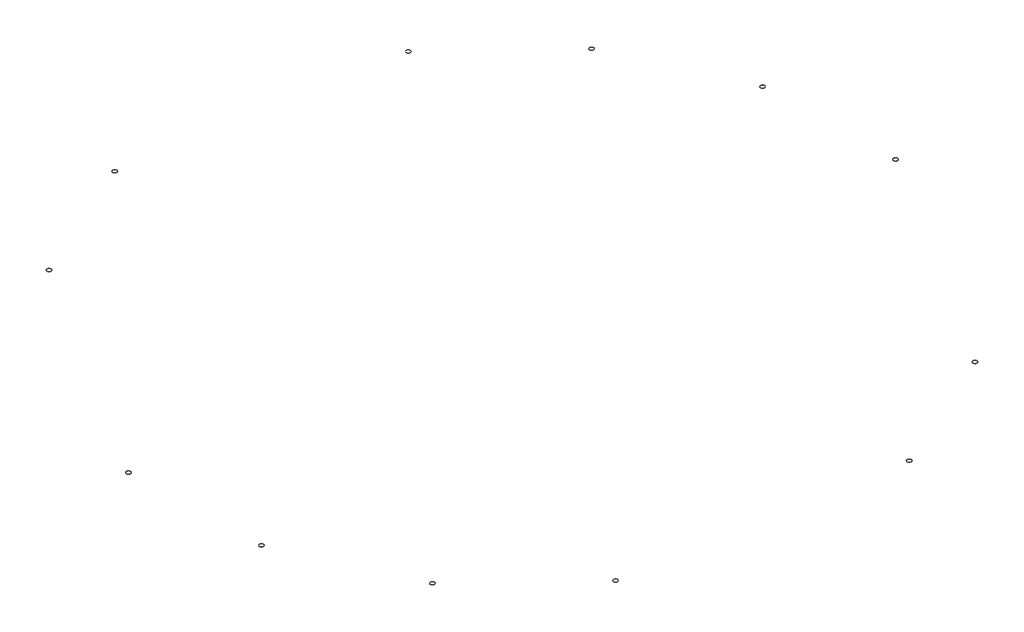
from build123d import *

# Parameters (mm, degrees)
SKETCH2_R              = 25.4
SKETCH2_R_2            = 22.225
BOSS_EXTRUDE1_DEPTH    = 3.175
BOSS_EXTRUDE1_2_DEPTH  = 3.175
BOSS_EXTRUDE1_3_DEPTH  = 3.175
BOSS_EXTRUDE1_4_DEPTH  = 3.175
BOSS_EXTRUDE1_5_DEPTH  = 3.175
BOSS_EXTRUDE1_6_DEPTH  = 3.175
BOSS_EXTRUDE1_7_DEPTH  = 3.175
BOSS_EXTRUDE1_8_DEPTH  = 3.175
BOSS_EXTRUDE1_9_DEPTH  = 3.175
BOSS_EXTRUDE1_10_DEPTH = 3.175
BOSS_EXTRUDE1_11_DEPTH = 3.175
BOSS_EXTRUDE1_12_DEPTH = 3.175


with BuildPart() as part:
    # Sketch2 → Boss-Extrude1 (new body)
    with BuildSketch(Plane(origin=(0, 0, 0), x_dir=(1, 0, 0), z_dir=(0, 1, 0))):
        with Locations((-3790.37532596, -857.674371981)):
            Circle(SKETCH2_R)
        with Locations((-3790.37532596, -857.674371981)):
            Circle(SKETCH2_R_2, mode=Mode.SUBTRACT)
    extrude(amount=BOSS_EXTRUDE1_DEPTH)


with BuildPart() as body_2:
    # Sketch2 → Boss-Extrude1 2 (new body)
    with BuildSketch(Plane(origin=(0, 0, 0), x_dir=(1, 0, 0), z_dir=(0, 1, 0))):
        with Locations((-3173.632411669, -2242.901637523)):
            Circle(SKETCH2_R)
        with Locations((-3173.632411669, -2242.901637523)):
            Circle(SKETCH2_R_2, mode=Mode.SUBTRACT)
    extrude(amount=BOSS_EXTRUDE1_2_DEPTH)


with BuildPart() as body_3:
    # Sketch2 → Boss-Extrude1 3 (new body)
    with BuildSketch(Plane(origin=(0, 0, 0), x_dir=(1, 0, 0), z_dir=(0, 1, 0))):
        with Locations((-658.126041858, -3830.067956712)):
            Circle(SKETCH2_R)
        with Locations((-658.126041858, -3830.067956712)):
            Circle(SKETCH2_R_2, mode=Mode.SUBTRACT)
    extrude(amount=BOSS_EXTRUDE1_3_DEPTH)


with BuildPart() as body_4:
    # Sketch2 → Boss-Extrude1 4 (new body)
    with BuildSketch(Plane(origin=(0, 0, 0), x_dir=(1, 0, 0), z_dir=(0, 1, 0))):
        with Locations((857.674371981, -3790.37532596)):
            Circle(SKETCH2_R)
        with Locations((857.674371981, -3790.37532596)):
            Circle(SKETCH2_R_2, mode=Mode.SUBTRACT)
    extrude(amount=BOSS_EXTRUDE1_4_DEPTH)


with BuildPart() as body_5:
    # Sketch2 → Boss-Extrude1 5 (new body)
    with BuildSketch(Plane(origin=(0, 0, 0), x_dir=(1, 0, 0), z_dir=(0, 1, 0))):
        with Locations((2242.901637523, -3173.632411669)):
            Circle(SKETCH2_R)
        with Locations((2242.901637523, -3173.632411669)):
            Circle(SKETCH2_R_2, mode=Mode.SUBTRACT)
    extrude(amount=BOSS_EXTRUDE1_5_DEPTH)


with BuildPart() as body_6:
    # Sketch2 → Boss-Extrude1 6 (new body)
    with BuildSketch(Plane(origin=(0, 0, 0), x_dir=(1, 0, 0), z_dir=(0, 1, 0))):
        with Locations((3286.667460706, -2073.732731751)):
            Circle(SKETCH2_R)
        with Locations((3286.667460706, -2073.732731751)):
            Circle(SKETCH2_R_2, mode=Mode.SUBTRACT)
    extrude(amount=BOSS_EXTRUDE1_6_DEPTH)


with BuildPart() as body_7:
    # Sketch2 → Boss-Extrude1 7 (new body)
    with BuildSketch(Plane(origin=(0, 0, 0), x_dir=(1, 0, 0), z_dir=(0, 1, 0))):
        with Locations((3790.37532596, 857.674371981)):
            Circle(SKETCH2_R)
        with Locations((3790.37532596, 857.674371981)):
            Circle(SKETCH2_R_2, mode=Mode.SUBTRACT)
    extrude(amount=BOSS_EXTRUDE1_7_DEPTH)


with BuildPart() as body_8:
    # Sketch2 → Boss-Extrude1 8 (new body)
    with BuildSketch(Plane(origin=(0, 0, 0), x_dir=(1, 0, 0), z_dir=(0, 1, 0))):
        with Locations((3173.632411669, 2242.901637523)):
            Circle(SKETCH2_R)
        with Locations((3173.632411669, 2242.901637523)):
            Circle(SKETCH2_R_2, mode=Mode.SUBTRACT)
    extrude(amount=BOSS_EXTRUDE1_8_DEPTH)


with BuildPart() as body_9:
    # Sketch2 → Boss-Extrude1 9 (new body)
    with BuildSketch(Plane(origin=(0, 0, 0), x_dir=(1, 0, 0), z_dir=(0, 1, 0))):
        with Locations((658.126041858, 3830.067956712)):
            Circle(SKETCH2_R)
        with Locations((658.126041858, 3830.067956712)):
            Circle(SKETCH2_R_2, mode=Mode.SUBTRACT)
    extrude(amount=BOSS_EXTRUDE1_9_DEPTH)


with BuildPart() as body_10:
    # Sketch2 → Boss-Extrude1 10 (new body)
    with BuildSketch(Plane(origin=(0, 0, 0), x_dir=(1, 0, 0), z_dir=(0, 1, 0))):
        with Locations((-857.674371981, 3790.37532596)):
            Circle(SKETCH2_R)
        with Locations((-857.674371981, 3790.37532596)):
            Circle(SKETCH2_R_2, mode=Mode.SUBTRACT)
    extrude(amount=BOSS_EXTRUDE1_10_DEPTH)


with BuildPart() as body_11:
    # Sketch2 → Boss-Extrude1 11 (new body)
    with BuildSketch(Plane(origin=(0, 0, 0), x_dir=(1, 0, 0), z_dir=(0, 1, 0))):
        with Locations((-2242.901637523, 3173.632411669)):
            Circle(SKETCH2_R)
        with Locations((-2242.901637523, 3173.632411669)):
            Circle(SKETCH2_R_2, mode=Mode.SUBTRACT)
    extrude(amount=BOSS_EXTRUDE1_11_DEPTH)


with BuildPart() as body_12:
    # Sketch2 → Boss-Extrude1 12 (new body)
    with BuildSketch(Plane(origin=(0, 0, 0), x_dir=(1, 0, 0), z_dir=(0, 1, 0))):
        with Locations((-3286.667460706, 2073.732731751)):
            Circle(SKETCH2_R)
        with Locations((-3286.667460706, 2073.732731751)):
            Circle(SKETCH2_R_2, mode=Mode.SUBTRACT)
    extrude(amount=BOSS_EXTRUDE1_12_DEPTH)


solid = Compound([part.part, body_2.part, body_3.part, body_4.part, body_5.part, body_6.part, body_7.part, body_8.part, body_9.part, body_10.part, body_11.part, body_12.part])
